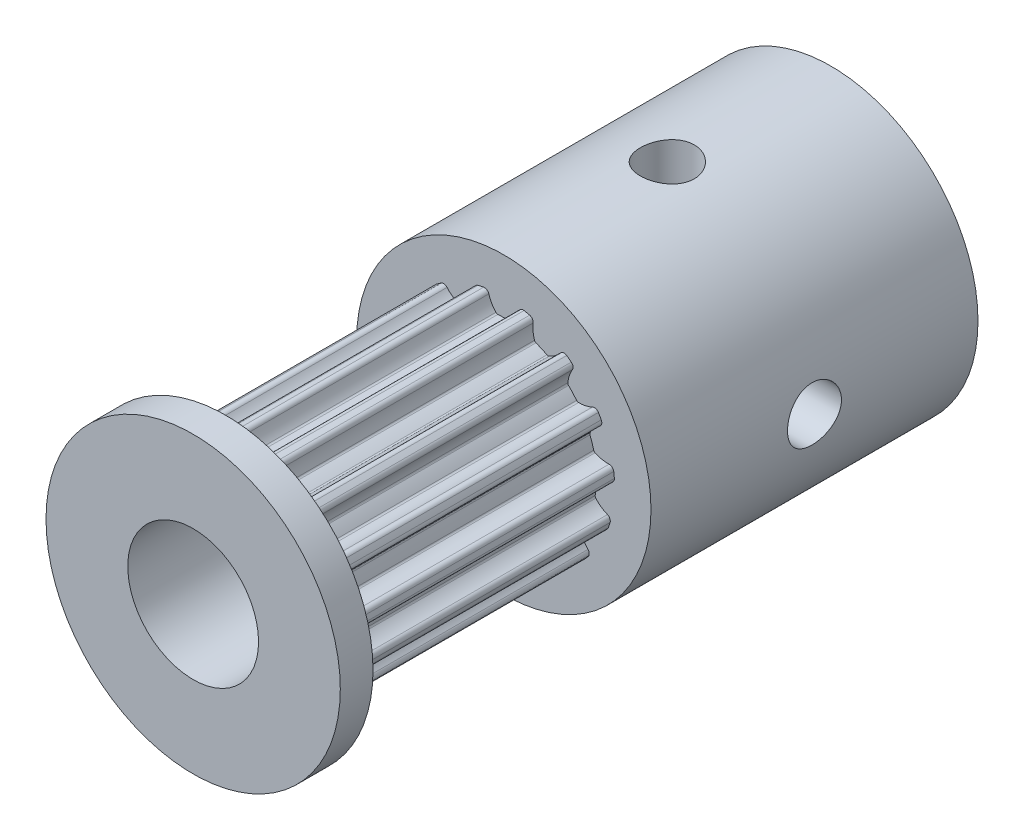
from build123d import *

# Parameters (mm, degrees)
SKETCH_1_R               = 6.78
EXTRUDE_1_DEPTH          = 8.5
CUT_EXTRUDE_START        = -18
CUT_EXTRUDE_1_DEPTH      = 19
PATTERN_CIRCULAR_1_COUNT = 15
SKETCH_3_R               = 9
EXTRUDE_2_DEPTH          = 2
SKETCH_5_R               = 9
EXTRUDE_3_DEPTH          = 20
SKETCH_4_R               = 4
CUT_EXTRUDE_2_DEPTH      = 40
SKETCH_7_W               = 1.65
SKETCH_7_H               = 9
PATTERN_CIRCULAR_2_COUNT = 2
PATTERN_CIRCULAR_2_ANGLE = 90


with BuildPart() as part:
    # 草圖1 → 填料-伸長1 (new body, symmetric)
    with BuildSketch(Plane.XY):
        Circle(SKETCH_1_R)
    extrude(amount=EXTRUDE_1_DEPTH, both=True)

    # 草圖2 → 除料-伸長1 (cut)
    with BuildSketch(Plane.XY.offset(8.5).offset(CUT_EXTRUDE_START)):
        with BuildLine():
            Line((-41.853470179, -0.873445946), (-1.237433728, 6.666120144))
            ThreePointArc((-1.237433728, 6.666120144), (-1.040214644, 6.629675034), (-0.917961101, 6.470685461))
            ThreePointArc((-0.917961101, 6.470685461), (-0.745770743, 6.064684237), (-0.487782161, 5.707013432))
            ThreePointArc((-0.487782161, 5.707013432), (-0.432967789, 5.668756858), (-0.366976411, 5.658111727))
            ThreePointArc((-0.366976411, 5.658111727), (0, 5.67), (0.366976411, 5.658111727))
            ThreePointArc((0.366976411, 5.658111727), (0.432967789, 5.668756858), (0.487782161, 5.707013432))
            ThreePointArc((0.487782161, 5.707013432), (0.745770743, 6.064684237), (0.917961101, 6.470685461))
            ThreePointArc((0.917961101, 6.470685461), (1.040214644, 6.629675034), (1.237433728, 6.666120144))
            Line((1.237433728, 6.666120144), (41.853470179, -0.873445946))
            Line((41.853470179, -0.873445946), (41.853470179, 81.746345238))
            Line((41.853470179, 81.746345238), (-41.853470179, 81.746345238))
            Line((-41.853470179, 81.746345238), (-41.853470179, -0.873445946))
        make_face()
    cut_extrude_1 = extrude(amount=CUT_EXTRUDE_1_DEPTH, mode=Mode.SUBTRACT)

    # 環狀複製排列1: 除料-伸長1 ×15 about axis
    pattern_circular_1_axis = Axis((0, 0, 8.5), (0, 0, 1))
    for i in range(1, PATTERN_CIRCULAR_1_COUNT):
        add(cut_extrude_1.rotate(pattern_circular_1_axis, i * 360 / PATTERN_CIRCULAR_1_COUNT), mode=Mode.SUBTRACT)

    # 草圖3 → 填料-伸長2 (add)
    with BuildSketch(Plane.XY.offset(8.5)):
        Circle(SKETCH_3_R)
    extrude(amount=EXTRUDE_2_DEPTH)

    # 草圖5 → 填料-伸長3 (add)
    with BuildSketch(Plane(origin=(0, 0, -8.5), x_dir=(-1, 0, 0), z_dir=(0, 0, -1))):
        Circle(SKETCH_5_R)
    extrude(amount=EXTRUDE_3_DEPTH)

    # 草圖4 → 除料-伸長2 (cut, through all)
    with BuildSketch(Plane.XY.offset(10.5)):
        Circle(SKETCH_4_R)
    extrude(amount=-CUT_EXTRUDE_2_DEPTH, mode=Mode.SUBTRACT)

    # 草圖7 → M4x0.7 螺紋孔1 (revolve, cut)
    with BuildSketch(Plane(origin=(0, 0, -18.5), x_dir=(0, 0, -1), z_dir=(1, 0, 0))):
        with Locations((0.825, 4.5)):
            Rectangle(SKETCH_7_W, SKETCH_7_H)
    m4x0_7_1 = revolve(axis=Axis((0, -6.35, -18.5), (0, 1, 0)), mode=Mode.SUBTRACT)

    # 環狀複製排列2: M4x0.7 螺紋孔1 ×2 about axis
    pattern_circular_2_axis = Axis((0, 0, -28.5), (0, 0, -1))
    for i in range(1, PATTERN_CIRCULAR_2_COUNT):
        add(m4x0_7_1.rotate(pattern_circular_2_axis, i * PATTERN_CIRCULAR_2_ANGLE / (PATTERN_CIRCULAR_2_COUNT - 1)), mode=Mode.SUBTRACT)


solid = part.part
